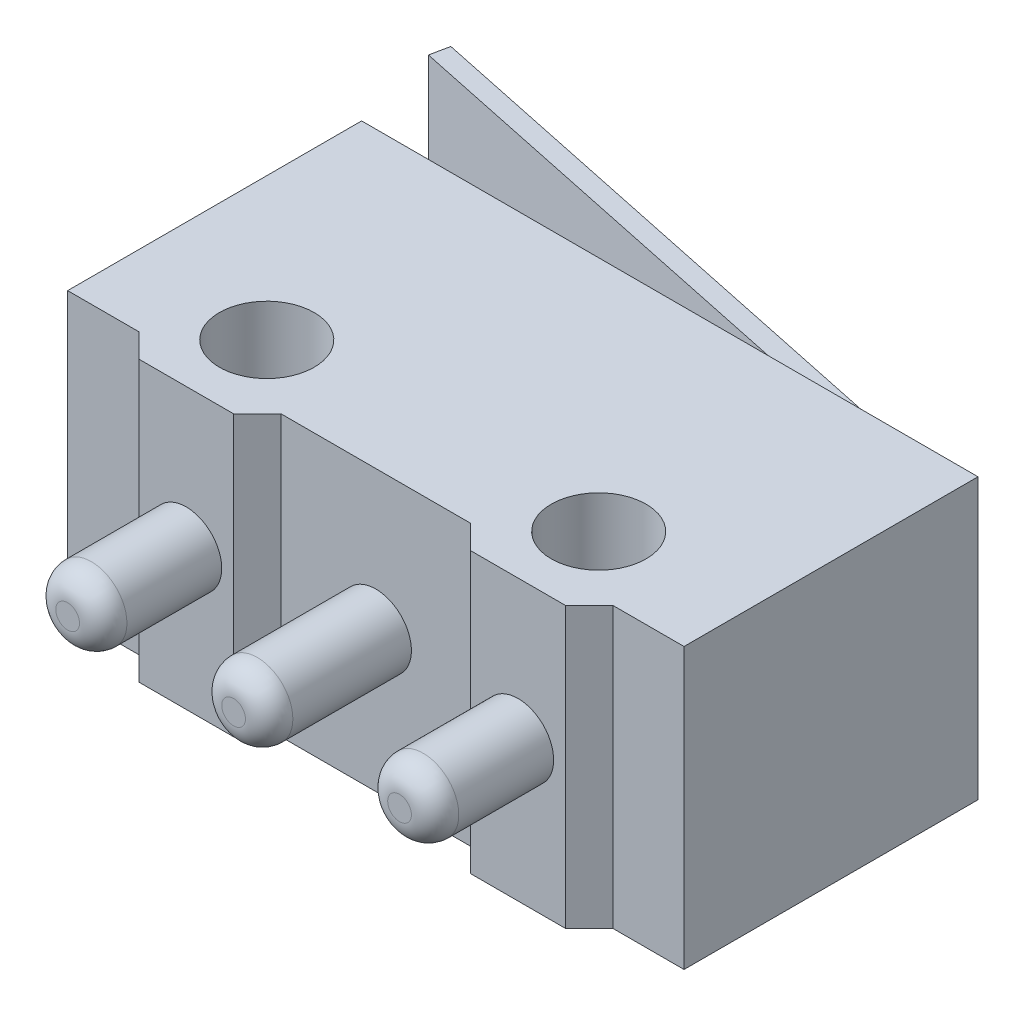
from build123d import *

# Parameters (mm, degrees)
SKETCH1_R           = 1
BOSS_EXTRUDE1_DEPTH = 2.95
CUT_EXTRUDE1_DEPTH  = 0.5
SKETCH3_R           = 0.75
BOSS_EXTRUDE2_DEPTH = 3
FILLET1_R           = 0.5


with BuildPart() as part:
    # Sketch1 → Boss-Extrude1 (new body, symmetric)
    with BuildSketch(Plane(origin=(0, 0, 0), x_dir=(1, 0, 0), z_dir=(0, 1, 0))):
        Polygon((-6.5, -3.1), (-5, -3.1), (-4.5, -3.6), (-2.5, -3.6), (-2, -3.1), (2, -3.1), (2.5, -3.6), (4.5, -3.6), (5, -3.1), (6.5, -3.1), (6.5, 3.1), (5.9, 3.1), (-7.417700692, 5.9), (-7.5, 5.50855802), (3.955876716, 3.1), (-6.5, 3.1), align=None)
        with Locations((3.5, -1.9)):
            Circle(SKETCH1_R, mode=Mode.SUBTRACT)
        with Locations((-3.5, -1.9)):
            Circle(SKETCH1_R, mode=Mode.SUBTRACT)
    extrude(amount=BOSS_EXTRUDE1_DEPTH, both=True)

    # Sketch2 → Cut-Extrude1 (cut)
    with BuildSketch(Plane(origin=(0, 2.95, 0), x_dir=(1, 0, 0), z_dir=(0, 1, 0))):
        Polygon((5.9, 3.1), (3.955876716, 3.1), (-7.5, 5.50855802), (-7.417700692, 5.9), align=None)
    cut_extrude1 = extrude(amount=-CUT_EXTRUDE1_DEPTH, mode=Mode.SUBTRACT)

    # Mirror1: Cut-Extrude1 across plane
    add(cut_extrude1.mirror(Plane.ZX), mode=Mode.SUBTRACT)

    # Sketch3 → Boss-Extrude2 (add)
    with BuildSketch(Plane.XY.offset(3.1)):
        Circle(SKETCH3_R)
        with Locations((-3.5, 0)):
            Circle(SKETCH3_R)
        with Locations((3.5, 0)):
            Circle(SKETCH3_R)
    extrude(amount=BOSS_EXTRUDE2_DEPTH)

    # Fillet1
    fillet1_edges = [part.edges().sort_by_distance(p)[0] for p in [
        (-0.75, 0, 6.1),
        (-4.25, 0, 6.1),
        (2.75, 0, 6.1),
    ]]
    fillet(fillet1_edges, radius=FILLET1_R)


solid = part.part
